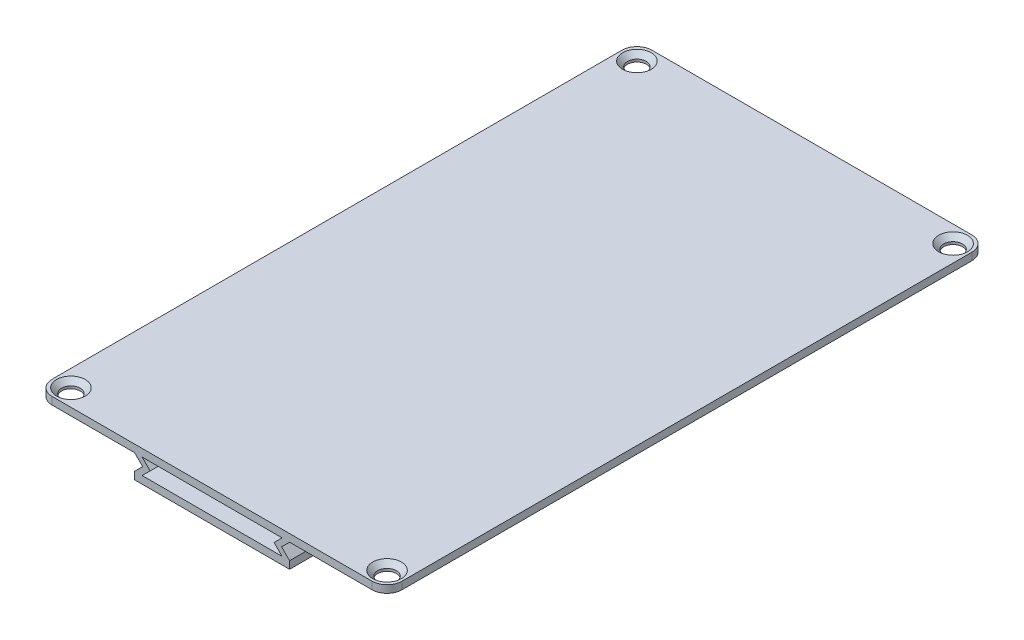
from build123d import *

# Parameters (mm, degrees)
BOSS_EXTRUDE1_DEPTH = 60
CUT_EXTRUDE1_START  = -7.2
SKETCH7_R           = 1.875
CUT_EXTRUDE1_DEPTH  = 8.2
CHAMFER1_SIZE       = 1
FILLET1_R           = 3


with BuildPart() as part:
    # Sketch2 → Boss-Extrude1 (new body, symmetric)
    with BuildSketch(Plane.XY):
        Polygon((0, 0), (-35, 0), (-35, -1.5), (-15.5, -1.5), (-13.9, -3.1), (-15.5, -4.7), (-15.5, -6.2), (0, -6.2), (0, -4.7), (-14, -4.7), (-12.4, -3.1), (-14, -1.5), (0, -1.5), align=None)
    boss_extrude1 = extrude(amount=BOSS_EXTRUDE1_DEPTH, both=True)

    # Sketch7 → Cut-Extrude1 (cut)
    with BuildSketch(Plane(origin=(0, 0, 0), x_dir=(1, 0, 0), z_dir=(0, 1, 0)).offset(CUT_EXTRUDE1_START)):
        with Locations((-31.625, 56.625)):
            Circle(SKETCH7_R)
        with Locations((-31.625, -56.625)):
            Circle(SKETCH7_R)
    cut_extrude1 = extrude(amount=CUT_EXTRUDE1_DEPTH, mode=Mode.SUBTRACT)

    # Mirror1: Boss-Extrude1, Cut-Extrude1 across plane
    add(boss_extrude1.mirror(Plane(origin=(0, -4.7, 60), x_dir=(0, 0, 1), z_dir=(-1, 0, 0))))
    add(cut_extrude1.mirror(Plane(origin=(0, -4.7, 60), x_dir=(0, 0, 1), z_dir=(-1, 0, 0))), mode=Mode.SUBTRACT)

    # Chamfer1
    chamfer1_edges = [part.edges().sort_by_distance(p)[0] for p in [
        (-33.5, 0, -56.625),
        (-33.5, 0, 56.625),
        (33.5, 0, -56.625),
        (33.5, 0, 56.625),
    ]]
    chamfer(chamfer1_edges, length=CHAMFER1_SIZE)

    # Fillet1
    fillet1_edges = [part.edges().sort_by_distance(p)[0] for p in [
        (-35, -0.75, 60),
        (-35, -0.75, -60),
        (35, -0.75, 60),
        (35, -0.75, -60),
    ]]
    fillet(fillet1_edges, radius=FILLET1_R)


solid = part.part
